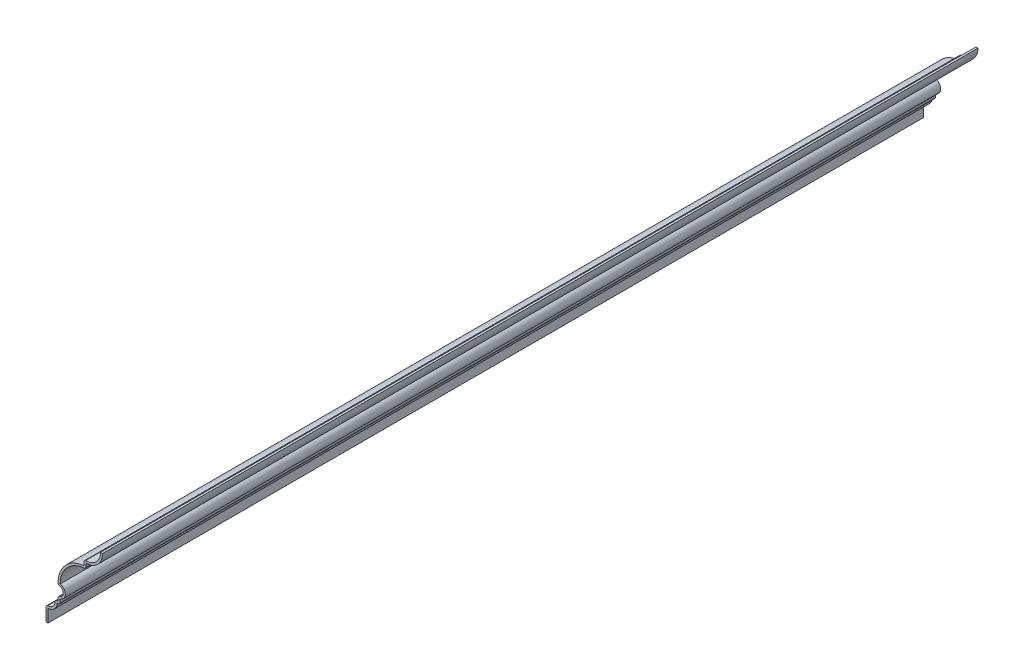
from build123d import *

# Parameters (mm, degrees)
EXTRUDE_THIN1_DEPTH = 539.75
FILLET1_R           = 1.27


with BuildPart() as part:
    # Sketch1 → Extrude-Thin1 (new body)
    with BuildSketch(Plane.XY):
        with BuildLine():
            Line((-33.655, 0), (-33.655, 7.9375))
            ThreePointArc((-33.655, 7.9375), (-29.726138, 9.564888), (-28.09875, 13.49375))
            Line((-28.09875, 13.49375), (-26.19375, 13.49375))
            Line((-26.19375, 13.49375), (-26.19375, 16.66875))
            ThreePointArc((-26.19375, 16.66875), (-23.01875, 20.6375), (-26.19375, 24.60625))
            ThreePointArc((-26.19375, 24.60625), (-21.54407, 35.83157), (-10.31875, 40.48125))
            Line((-10.31875, 40.48125), (-10.31875, 43.65625))
            ThreePointArc((-10.31875, 43.65625), (-3.022292, 46.678542), (0, 53.975))
            Line((0, 53.975), (-1.27, 53.975))
            ThreePointArc((-1.27, 53.975), (-4.386298, 47.142292), (-11.58875, 45.015816))
            Line((-11.58875, 45.015816), (-11.58875, 41.704148))
            ThreePointArc((-11.58875, 41.704148), (-23.280923, 35.828241), (-27.422334, 23.415267))
            ThreePointArc((-27.422334, 23.415267), (-24.288828, 20.616622), (-27.46375, 17.86505))
            Line((-27.46375, 17.86505), (-27.46375, 14.76375))
            Line((-27.46375, 14.76375), (-29.561219, 14.76375))
            ThreePointArc((-29.561219, 14.76375), (-30.624164, 10.462914), (-34.925, 9.399969))
            Line((-34.925, 9.399969), (-34.925, 0))
            Line((-34.925, 0), (-33.655, 0))
        make_face()
    extrude(amount=-EXTRUDE_THIN1_DEPTH)

    # Fillet1
    fillet1_edges = [part.edges().sort_by_distance(p)[0] for p in [
        (-10.31875, 40.48125, -269.875),
        (-26.19375, 13.49375, -269.875),
        (-34.925, 9.399969, -269.875),
        (-29.561219, 14.76375, -269.875),
        (-27.46375, 17.86505, -269.875),
        (-27.422334, 23.415267, -269.875),
        (-11.58875, 45.015816, -269.875),
    ]]
    fillet(fillet1_edges, radius=FILLET1_R)


solid = part.part
